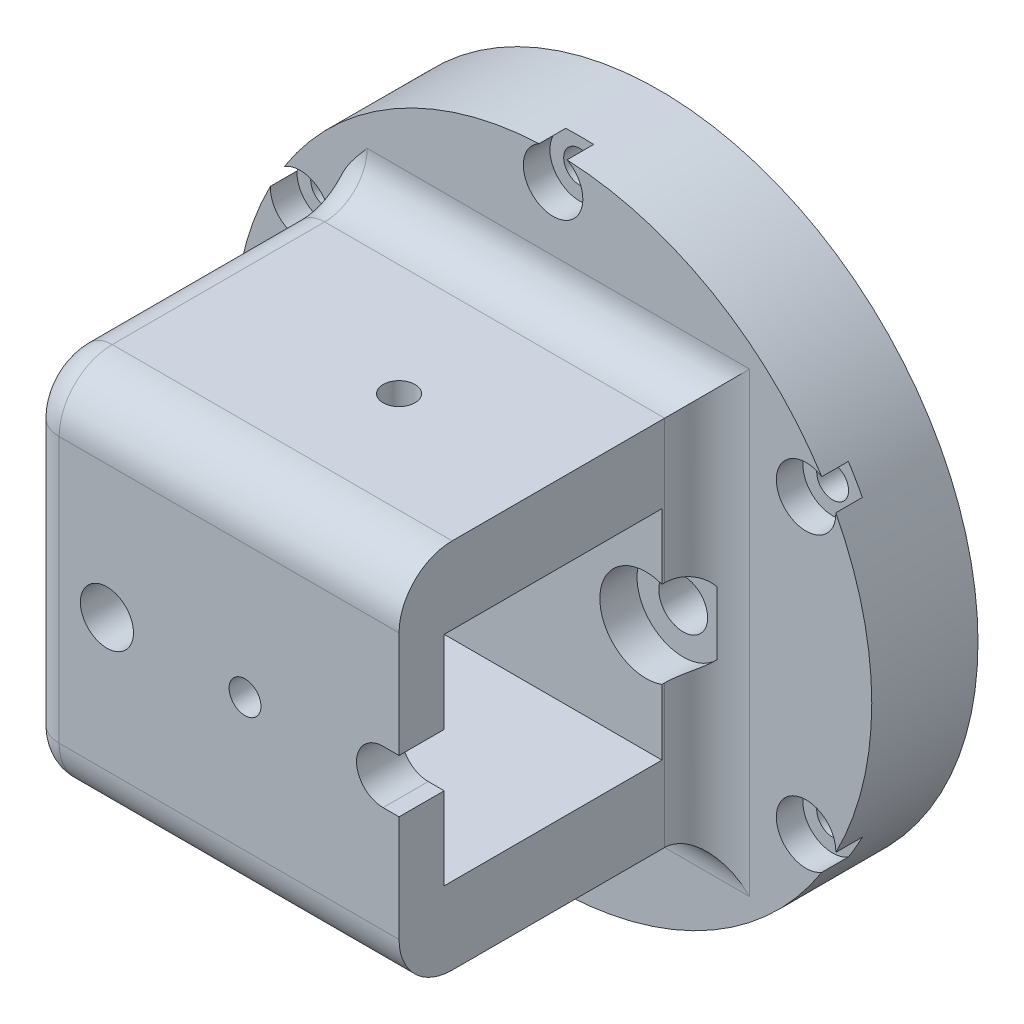
from build123d import *

# Parameters (mm, degrees)
SCHIZZO1_R                   = 30
SCHIZZO1_R_2                 = 21
ESTRUSIONE_ESTRUSIONE1_DEPTH = 5
SCHIZZO7_R                   = 30
ESTRUSIONE_ESTRUSIONE2_DEPTH = 5
SCHIZZO3_R                   = 1.5
TAGLIO_ESTRUSIONE3_DEPTH     = 8
SCHIZZO10_R                  = 2.8
TAGLIO_ESTRUSIONE4_DEPTH     = 2.5
RIPETIZIONECIRCOLARE1_COUNT  = 6
SCHIZZO11_W                  = 14.5
SCHIZZO11_H                  = 17.5
ESTRUSIONE_ESTRUSIONE4_DEPTH = 29
SCHIZZO12_W                  = 20.5
SCHIZZO12_H                  = 20.5
TAGLIO_ESTRUSIONE5_DEPTH     = 31
RACCORDO3_R                  = 5
SCHIZZO13_R                  = 1.5
TAGLIO_ESTRUSIONE6_DEPTH     = 69.390423306
SCHIZZO14_R                  = 1.5
TAGLIO_ESTRUSIONE7_DEPTH     = 20
RACCORDO4_R                  = 4
RACCORDO5_R                  = 3
TAGLIO_ESTRUSIONE10_REACH    = 56.369
SCHIZZO15_R                  = 2.3
SCHIZZO16_R                  = 16.25
SCHIZZO16_R_2                = 2.3
TAGLIO_ESTRUSIONE11_DEPTH    = 2
SCHIZZO17_R                  = 4.35
TAGLIO_ESTRUSIONE12_DEPTH    = 3.5
SCHIZZO18_R                  = 4.35
TAGLIO_ESTRUSIONE13_DEPTH    = 20.5
SCHIZZO20_R                  = 2.5
TAGLIO_ESTRUSIONE14_DEPTH    = 50.117843051


with BuildPart() as part:
    # Schizzo1 → Estrusione-Estrusione1 (new body)
    with BuildSketch(Plane.XY):
        Circle(SCHIZZO1_R)
        Circle(SCHIZZO1_R_2, mode=Mode.SUBTRACT)
    extrude(amount=ESTRUSIONE_ESTRUSIONE1_DEPTH)

    # Schizzo7 → Estrusione-Estrusione2 (add)
    with BuildSketch(Plane.XY.offset(5)):
        Circle(SCHIZZO7_R)
    extrude(amount=ESTRUSIONE_ESTRUSIONE2_DEPTH)

    # Schizzo3 → Taglio-Estrusione3 (cut)
    with BuildSketch(Plane.XY):
        with Locations((0, 27.5)):
            Circle(SCHIZZO3_R)
    taglio_estrusione3 = extrude(amount=TAGLIO_ESTRUSIONE3_DEPTH, mode=Mode.SUBTRACT)

    # Schizzo10 → Taglio-Estrusione4 (cut)
    with BuildSketch(Plane.XY.offset(10)):
        with Locations((0, 27.5)):
            Circle(SCHIZZO10_R)
    taglio_estrusione4 = extrude(amount=-TAGLIO_ESTRUSIONE4_DEPTH, mode=Mode.SUBTRACT)

    # RipetizioneCircolare1: Taglio-Estrusione3, Taglio-Estrusione4 ×6 about axis
    ripetizionecircolare1_axis = Axis((0, 0, 0), (0, 0, 1))
    add([taglio_estrusione3.rotate(ripetizionecircolare1_axis, i * 360 / RIPETIZIONECIRCOLARE1_COUNT) for i in range(1, RIPETIZIONECIRCOLARE1_COUNT)], mode=Mode.SUBTRACT)
    add([taglio_estrusione4.rotate(ripetizionecircolare1_axis, i * 360 / RIPETIZIONECIRCOLARE1_COUNT) for i in range(1, RIPETIZIONECIRCOLARE1_COUNT)], mode=Mode.SUBTRACT)

    # Schizzo11 → Estrusione-Estrusione4 (add)
    with BuildSketch(Plane.XY.offset(10)):
        Polygon((-14.5, 17.5), (14.5, -17.5), (-14.5, -17.5), (-20.5, -17.5), (-20.5, 17.5), align=None)
        Polygon((0, 17.5), (-14.5, 17.5), (0, 0), align=None)
        with Locations((7.25, 8.75)):
            Rectangle(SCHIZZO11_W, SCHIZZO11_H)
        Polygon((14.5, 0), (0, 0), (14.5, -17.5), align=None)
    extrude(amount=ESTRUSIONE_ESTRUSIONE4_DEPTH)

    # Schizzo12 → Taglio-Estrusione5 (cut)
    with BuildSketch(Plane(origin=(14.5, 0, 0), x_dir=(0, 0, -1), z_dir=(1, 0, 0))):
        with Locations((-24.5, 0)):
            Rectangle(SCHIZZO12_W, SCHIZZO12_H)
    extrude(amount=-TAGLIO_ESTRUSIONE5_DEPTH, mode=Mode.SUBTRACT)

    # Raccordo3
    raccordo3_edges = [part.edges().sort_by_distance(p)[0] for p in [
        (-3, 17.5, 39),
        (-3, -17.5, 39),
    ]]
    fillet(raccordo3_edges, radius=RACCORDO3_R)

    # Schizzo13 → Taglio-Estrusione6 (cut, through all)
    with BuildSketch(Plane.XZ.offset(17.5)):
        with Locations(Location((0, 24.5, 0), (0, 0, 270))):
            Circle(SCHIZZO13_R)
    extrude(amount=-TAGLIO_ESTRUSIONE6_DEPTH, mode=Mode.SUBTRACT)

    # Schizzo14 → Taglio-Estrusione7 (cut)
    with BuildSketch(Plane.XY.offset(39)):
        Circle(SCHIZZO14_R)
    extrude(amount=-TAGLIO_ESTRUSIONE7_DEPTH, mode=Mode.SUBTRACT)

    # Raccordo4
    raccordo4_edges = [part.edges().sort_by_distance(p)[0] for p in [
        (14.5, 0, 10),
        (-3, -17.5, 10),
        (-3, 17.5, 10),
    ]]
    fillet(raccordo4_edges, radius=RACCORDO4_R)

    # Raccordo5
    raccordo5_edges = [part.edges().sort_by_distance(p)[0] for p in [
        (-20.5, -17.5, 24),
        (-20.5, 0, 39),
        (-20.5, 17.5, 24),
        (-20.5, 16.035533906, 37.535533906),
        (-20.5, -16.035533906, 37.535533906),
        (-20.5, 18.671572875, 11.171572875),
        (-20.5, -18.671572875, 11.171572875),
    ]]
    fillet(raccordo5_edges, radius=RACCORDO5_R)

    # Taglio-Estrusione10: up to this face of the body (flat: up to its plane)
    taglio_estrusione10_end = Plane(part.part.faces().sort_by_distance((-1, 0, 14.25))[0])
    # Schizzo15 → Taglio-Estrusione10 (cut, up to the picked face)
    with BuildSketch(Plane(origin=(0, 0, 5), x_dir=(-1, 0, 0), z_dir=(0, 0, -1)), mode=Mode.PRIVATE) as taglio_estrusione10_sk1:
        with Locations((13, 0)):
            Circle(SCHIZZO15_R)
    taglio_estrusione10_tool1 = split(extrude(taglio_estrusione10_sk1.sketch, amount=-TAGLIO_ESTRUSIONE10_REACH, mode=Mode.PRIVATE), bisect_by=taglio_estrusione10_end, keep=Keep.BOTH, mode=Mode.PRIVATE)
    # Schizzo15 → Taglio-Estrusione10 (cut, up to the picked face)
    with BuildSketch(Plane(origin=(0, 0, 5), x_dir=(-1, 0, 0), z_dir=(0, 0, -1)), mode=Mode.PRIVATE) as taglio_estrusione10_sk2:
        with Locations((-13, 0)):
            Circle(SCHIZZO15_R)
    taglio_estrusione10_tool2 = split(extrude(taglio_estrusione10_sk2.sketch, amount=-TAGLIO_ESTRUSIONE10_REACH, mode=Mode.PRIVATE), bisect_by=taglio_estrusione10_end, keep=Keep.BOTH, mode=Mode.PRIVATE)
    add(taglio_estrusione10_tool1.solids().sort_by(Axis((-13, 0, 5), (0, 0, 1)))[0], mode=Mode.SUBTRACT)
    add(taglio_estrusione10_tool2.solids().sort_by(Axis((13, 0, 5), (0, 0, 1)))[0], mode=Mode.SUBTRACT)

    # Schizzo16 → Taglio-Estrusione11 (cut)
    with BuildSketch(Plane(origin=(0, 0, 5), x_dir=(-1, 0, 0), z_dir=(0, 0, -1))):
        Circle(SCHIZZO16_R)
        with Locations((-13, 0)):
            Circle(SCHIZZO16_R_2, mode=Mode.SUBTRACT)
        with Locations((13, 0)):
            Circle(SCHIZZO16_R_2, mode=Mode.SUBTRACT)
    extrude(amount=-TAGLIO_ESTRUSIONE11_DEPTH, mode=Mode.SUBTRACT)

    # Schizzo17 → Taglio-Estrusione12 (cut)
    with BuildSketch(Plane.XY.offset(14.25)):
        with Locations((-13, 0)):
            Circle(SCHIZZO17_R)
        with Locations((13, 0)):
            Circle(SCHIZZO17_R)
    extrude(amount=-TAGLIO_ESTRUSIONE12_DEPTH, mode=Mode.SUBTRACT)

    # Schizzo18 → Taglio-Estrusione13 (cut)
    with BuildSketch(Plane.XY.offset(14.25)):
        with Locations((-13, 0)):
            Circle(SCHIZZO18_R)
        with Locations((13, 0)):
            Circle(SCHIZZO18_R)
    extrude(amount=TAGLIO_ESTRUSIONE13_DEPTH, mode=Mode.SUBTRACT)

    # Schizzo20 → Taglio-Estrusione14 (cut, through all)
    with BuildSketch(Plane.XY.offset(14.25)):
        with Locations((-13, 0)):
            Circle(SCHIZZO20_R)
        with BuildLine():
            Line((13, 2.5), (15.5, 2.5))
            Line((15.5, 2.5), (15.5, -2.5))
            Line((15.5, -2.5), (13, -2.5))
            ThreePointArc((13, -2.5), (10.5, 0), (13, 2.5))
        make_face()
    extrude(amount=TAGLIO_ESTRUSIONE14_DEPTH, mode=Mode.SUBTRACT)


solid = part.part
